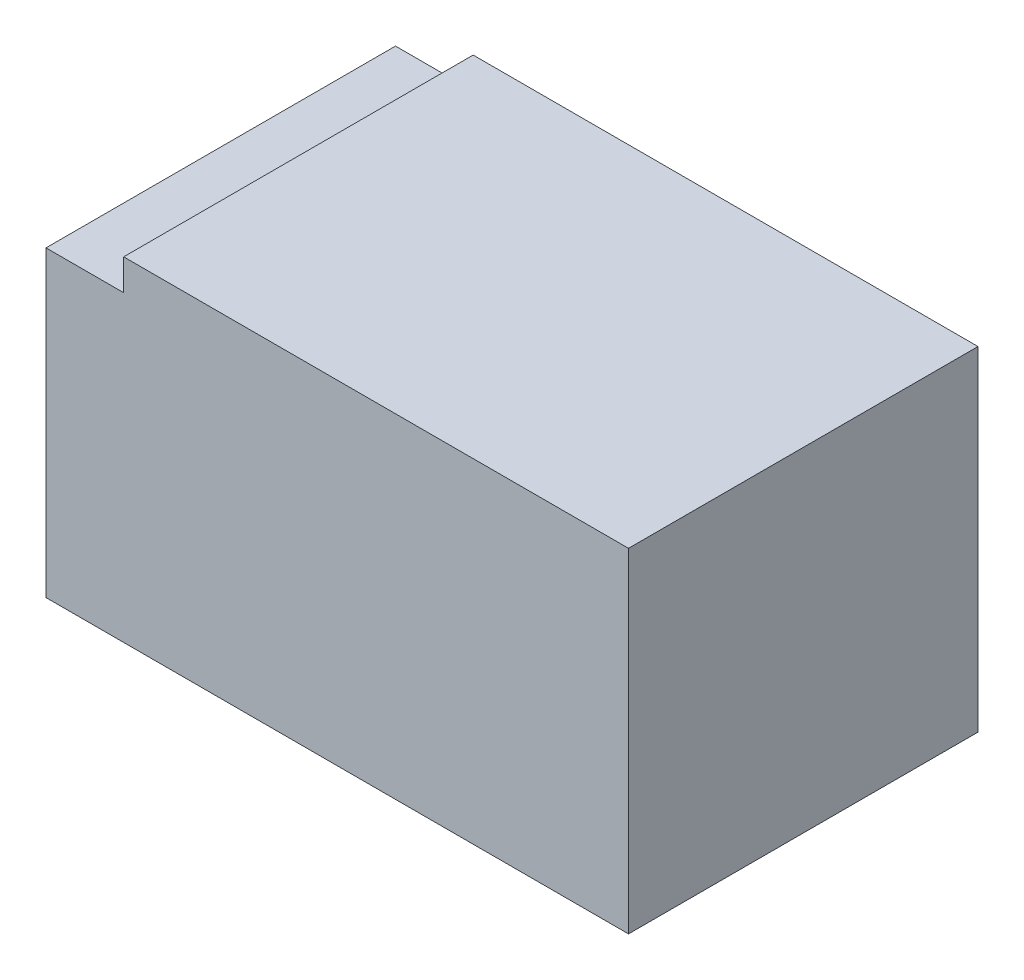
from build123d import *

# Parameters (mm, degrees)
EXTRUDE_1_DEPTH = 90


with BuildPart() as part:
    # 草图1 → 凸台-拉伸1 (new body)
    with BuildSketch(Plane.XY):
        Polygon((0, 0), (150, 0), (150, 86), (20, 86), (20, 78), (0, 78), align=None)
    extrude(amount=EXTRUDE_1_DEPTH)


solid = part.part
